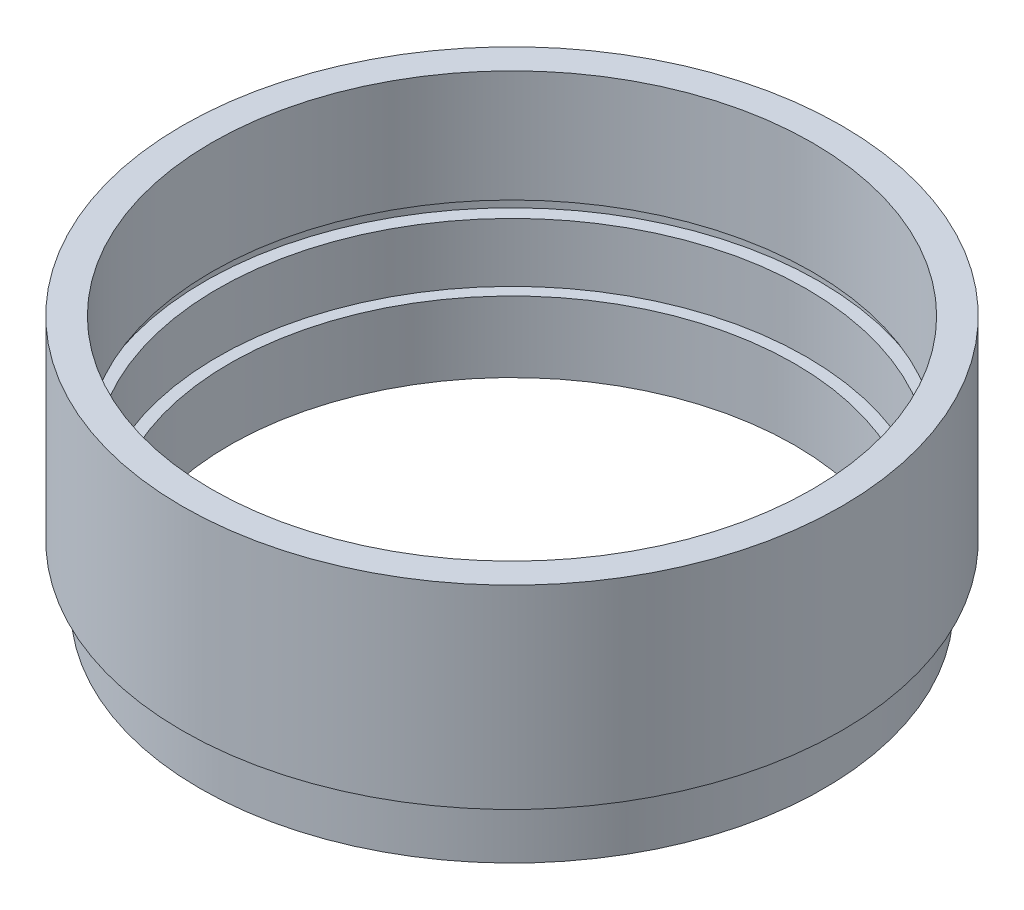
from build123d import *


with BuildPart() as part:
    # 草图1 → 旋转1 (revolve)
    with BuildSketch(Plane.XY, mode=Mode.PRIVATE) as revolve_1_sk:
        Polygon((24, 0), (26.5, 0), (26.5, 4), (25.5, 4), (25.5, 5), (28, 5), (28, 21.5), (25.5, 21.5), (25.5, 12), (26.1, 12), (26.1, 11), (25, 11), (25, 6), (24, 6), align=None)
    revolve(revolve_1_sk.sketch.rotate(Axis((0, 0, 0), (0, 1, 0)), 90), axis=Axis((0, 0, 0), (0, 1, 0)))  # turned: the seam where the file's is


solid = part.part
